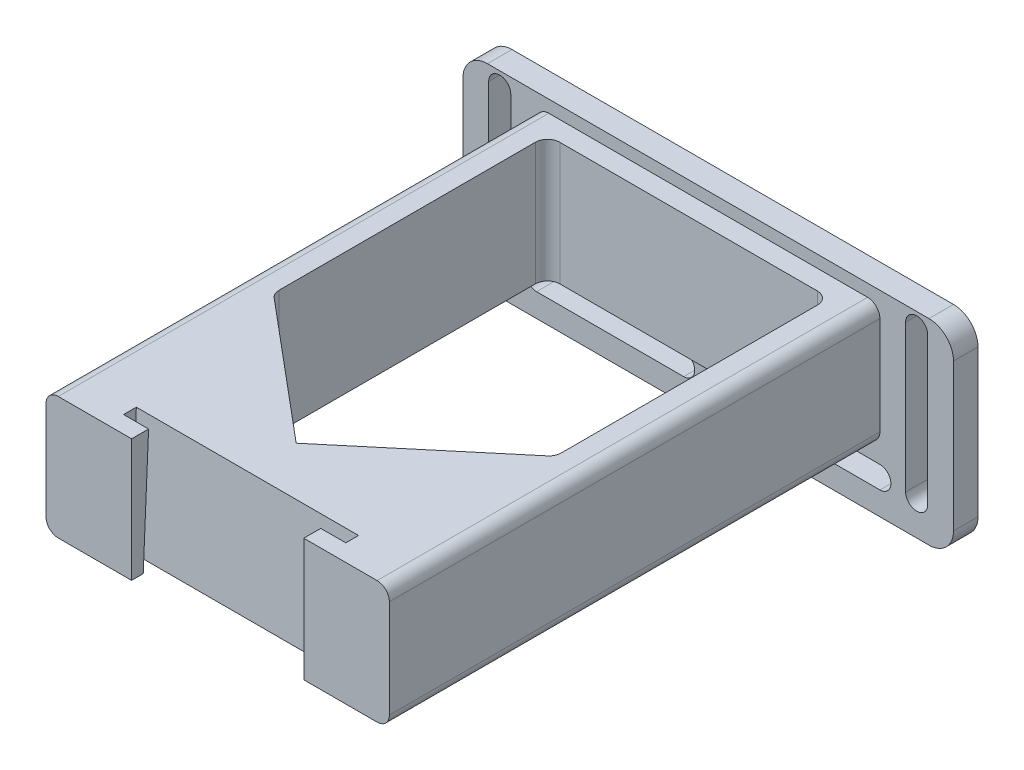
from build123d import *

# Parameters (mm, degrees)
SKETCH1_W               = 100
SKETCH1_H               = 40
BOSS_EXTRUDE1_DEPTH     = 5
CUT_EXTRUDE1_DEPTH      = 5
CUT_EXTRUDE2_DEPTH      = 5
CUT_EXTRUDE3_DEPTH      = 5
CUT_EXTRUDE4_DEPTH      = 5
SKETCH3_W               = 70
SKETCH3_H               = 25
BOSS_EXTRUDE2_DEPTH     = 100
FILLET1_R               = 5
FILLET2_R               = 2.5
CUT_EXTRUDE8_DEPTH      = 120.504184027
FILLET3_R               = 2.5
CUT_EXTRUDE9_DEPTH      = 122.347977614
CUT_EXTRUDE9_DEPTH_BACK = 122.347977614


with BuildPart() as part:
    # Sketch1 → Boss-Extrude1 (new body)
    with BuildSketch(Plane.XY):
        Rectangle(SKETCH1_W, SKETCH1_H)
    extrude(amount=BOSS_EXTRUDE1_DEPTH)

    # Sketch2 → Cut-Extrude1 (cut)
    with BuildSketch(Plane.XY.offset(5)):
        with BuildLine():
            Line((-40.25, 17), (-40.25, -13))
            ThreePointArc((-40.25, -13), (-42.5, -15.25), (-44.75, -13))
            Line((-44.75, -13), (-44.75, 17))
            ThreePointArc((-44.75, 17), (-42.5, 19.25), (-40.25, 17))
        make_face()
    extrude(amount=-CUT_EXTRUDE1_DEPTH, mode=Mode.SUBTRACT)

    # Sketch2_3 → Cut-Extrude2 (cut)
    with BuildSketch(Plane.XY.offset(5)):
        with BuildLine():
            Line((-35, -10.75), (-5, -10.75))
            ThreePointArc((-5, -10.75), (-2.75, -13), (-5, -15.25))
            Line((-5, -15.25), (-35, -15.25))
            ThreePointArc((-35, -15.25), (-37.25, -13), (-35, -10.75))
        make_face()
    extrude(amount=-CUT_EXTRUDE2_DEPTH, mode=Mode.SUBTRACT)

    # Sketch2_4 → Cut-Extrude3 (cut)
    with BuildSketch(Plane.XY.offset(5)):
        with BuildLine():
            Line((5, -10.75), (35, -10.75))
            ThreePointArc((35, -10.75), (37.25, -13), (35, -15.25))
            Line((35, -15.25), (5, -15.25))
            ThreePointArc((5, -15.25), (2.75, -13), (5, -10.75))
        make_face()
    extrude(amount=-CUT_EXTRUDE3_DEPTH, mode=Mode.SUBTRACT)

    # Sketch2_5 → Cut-Extrude4 (cut)
    with BuildSketch(Plane.XY.offset(5)):
        with BuildLine():
            Line((44.75, 17), (44.75, -13))
            ThreePointArc((44.75, -13), (42.5, -15.25), (40.25, -13))
            Line((40.25, -13), (40.25, 17))
            ThreePointArc((40.25, 17), (42.5, 19.25), (44.75, 17))
        make_face()
    extrude(amount=-CUT_EXTRUDE4_DEPTH, mode=Mode.SUBTRACT)

    # Sketch3 → Boss-Extrude2 (add)
    with BuildSketch(Plane.XY.offset(5)):
        with Locations((0, 5)):
            Rectangle(SKETCH3_W, SKETCH3_H)
    extrude(amount=BOSS_EXTRUDE2_DEPTH)

    # Fillet1
    fillet1_edges = [part.edges().sort_by_distance(p)[0] for p in [
        (-50, 20, 2.5),
        (50, 20, 2.5),
        (50, -20, 2.5),
        (-50, -20, 2.5),
    ]]
    fillet(fillet1_edges, radius=FILLET1_R)

    # Fillet2
    fillet2_edges = [part.edges().sort_by_distance(p)[0] for p in [
        (-35, 17.5, 55),
        (35, 17.5, 55),
        (35, -7.5, 55),
        (-35, -7.5, 55),
    ]]
    fillet(fillet2_edges, radius=FILLET2_R)

    # Sketch8 → Cut-Extrude8 (cut, through all)
    with BuildSketch(Plane.XZ.offset(7.5)):
        Polygon((-28.75, 9), (28.75, 9), (28.75, 64.875885604), (0, 89), (-28.75, 64.875885604), align=None)
    extrude(amount=-CUT_EXTRUDE8_DEPTH, mode=Mode.SUBTRACT)

    # Fillet3
    fillet3_edges = [part.edges().sort_by_distance(p)[0] for p in [
        (28.75, 5, 64.875885604),
        (-28.75, 5, 64.875885604),
        (28.75, 5, 9),
        (-28.75, 5, 9),
    ]]
    fillet(fillet3_edges, radius=FILLET3_R)

    # Sketch9 → Cut-Extrude9 (cut, two sides: drawn at the far end of the back side and taken through both)
    with BuildSketch(Plane(origin=(0, 12.891027114, -0.562834399), x_dir=(-1, 0, 0), z_dir=(0, 0.9990482215818578, -0.0436193873653361)).offset(-CUT_EXTRUDE9_DEPTH_BACK)):
        Polygon((17.55, 102.203377148), (22.65, 102.203377148), (22.65, 99.603377148), (-22.65, 99.603377148), (-22.65, 102.203377148), (-17.55, 102.203377148), (-17.55, 108.905331005), (17.55, 108.905331005), align=None)
    extrude(amount=CUT_EXTRUDE9_DEPTH + CUT_EXTRUDE9_DEPTH_BACK, mode=Mode.SUBTRACT)


solid = part.part
